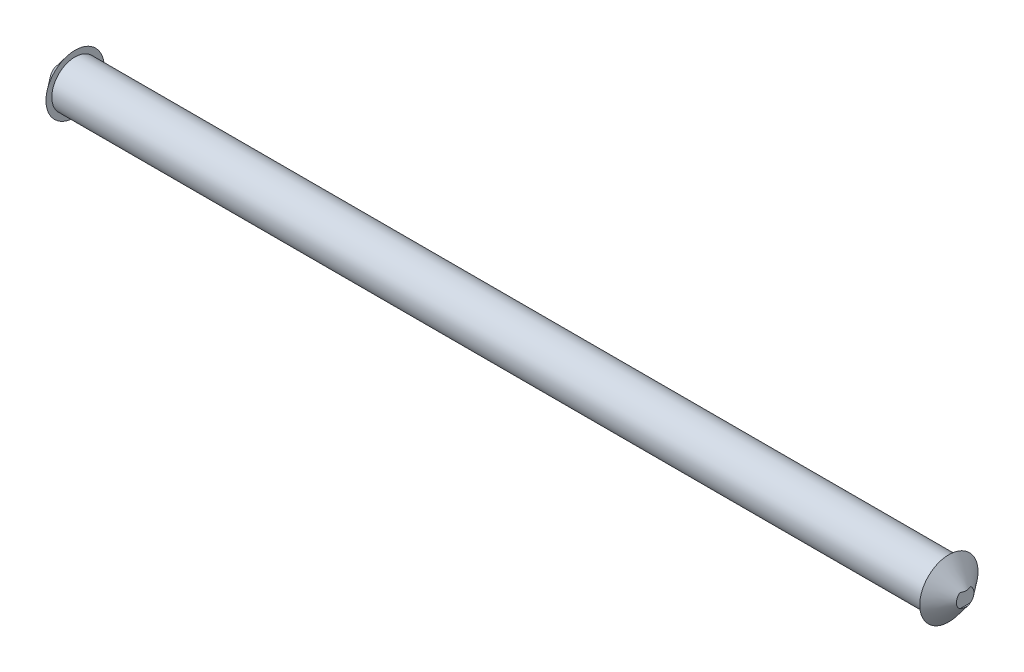
from build123d import *

# Parameters (mm, degrees)
SKETCH1_R           = 10
BOSS_EXTRUDE1_DEPTH = 187.5
SKETCH3_R           = 12.5
CUT_EXTRUDE1_START  = -199.289561108
SKETCH4_W           = 4
SKETCH4_H           = 6
CUT_EXTRUDE1_DEPTH  = 209.289561108


with BuildPart() as part:
    # Sketch1 → Boss-Extrude1 (new, symmetric)
    with BuildSketch(Plane(origin=(0, 0, 0), x_dir=(0, 0, -1), z_dir=(1, 0, 0))):
        Circle(SKETCH1_R)
    extrude(amount=BOSS_EXTRUDE1_DEPTH, both=True)

    # Sketch3 → Loft1 section 0
    with BuildSketch(Plane(origin=(187.5, 0, 0), x_dir=(0, 0, -1), z_dir=(1, 0, 0)), mode=Mode.PRIVATE) as loft1_s0:
        Circle(SKETCH3_R)
    loft1 = loft([Vertex(197.5, 0, 0), loft1_s0.sketch])

    # Mirror1: Loft1 across plane
    add(loft1.mirror(Plane(origin=(0, 0, 0), x_dir=(0, 0, 1), z_dir=(1, 0, 0))))

    # Sketch4 → Cut-Extrude1 (cut)
    with BuildSketch(Plane.XY.offset(CUT_EXTRUDE1_START)):
        with Locations((196.492262498, 0)):
            Rectangle(SKETCH4_W, SKETCH4_H)
    cut_extrude1 = extrude(amount=CUT_EXTRUDE1_DEPTH, mode=Mode.SUBTRACT)

    # Mirror2: Cut-Extrude1 across plane
    add(cut_extrude1.mirror(Plane(origin=(0, 0, 0), x_dir=(0, 0, 1), z_dir=(1, 0, 0))), mode=Mode.SUBTRACT)


solid = part.part
